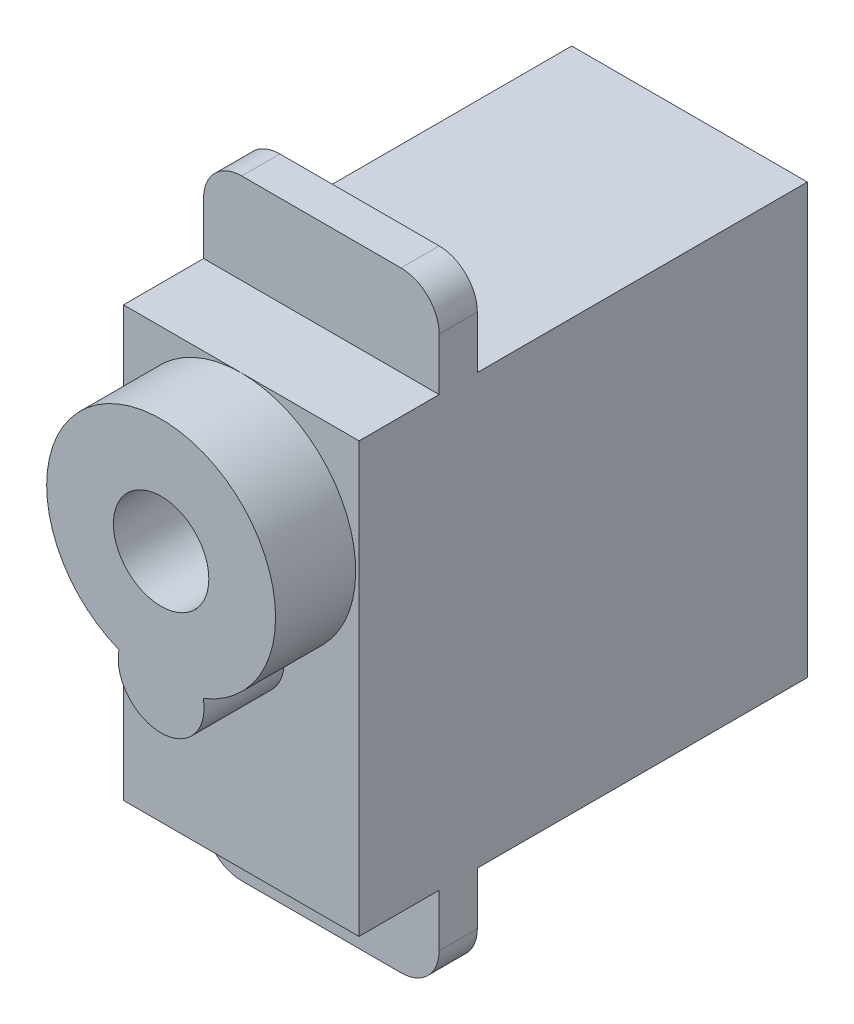
from build123d import *

# Parameters (mm, degrees)
SKETCH3_W           = 22.5
SKETCH3_H           = 23.5
BOSS_EXTRUDE1_DEPTH = 6.175
SKETCH4_W           = 12.35
SKETCH4_H           = 32
BOSS_EXTRUDE2_DEPTH = 2
BOSS_EXTRUDE3_DEPTH = 4.2
SKETCH6_R           = 2.5
CUT_EXTRUDE1_DEPTH  = 4.2
FILLET1_R           = 2


with BuildPart() as part:
    # Sketch3 → Boss-Extrude1 (new body, symmetric)
    with BuildSketch(Plane(origin=(0, -28.275548605, 0), x_dir=(0, 1, 0), z_dir=(1, 0, 0))):
        with Locations((24.609729517, 167.116706922)):
            Rectangle(SKETCH3_W, SKETCH3_H)
    extrude(amount=BOSS_EXTRUDE1_DEPTH, both=True)

    # Sketch4 → Boss-Extrude2 (add)
    with BuildSketch(Plane.XY.offset(174.666706922)):
        with Locations((0, -3.665819089)):
            Rectangle(SKETCH4_W, SKETCH4_H)
    extrude(amount=-BOSS_EXTRUDE2_DEPTH)

    # Sketch5 → Boss-Extrude3 (add)
    with BuildSketch(Plane.XY.offset(178.866706922)):
        with BuildLine():
            ThreePointArc((2.210095356, -3.993944089), (0, 7.584180911), (-2.210095356, -3.993944089))
            ThreePointArc((-2.210095356, -3.993944089), (0, -6.665819089), (2.210095356, -3.993944089))
        make_face()
    extrude(amount=BOSS_EXTRUDE3_DEPTH)

    # Sketch6 → Cut-Extrude1 (cut)
    with BuildSketch(Plane.XY.offset(183.066706922)):
        with Locations((0, 1.584180911)):
            Circle(SKETCH6_R)
    extrude(amount=-CUT_EXTRUDE1_DEPTH, mode=Mode.SUBTRACT)

    # Fillet1
    fillet1_edges = [part.edges().sort_by_distance(p)[0] for p in [
        (-6.175, -19.665819089, 173.666706922),
        (6.175, 12.334180911, 173.666706922),
        (-6.175, 12.334180911, 173.666706922),
        (6.175, -19.665819089, 173.666706922),
    ]]
    fillet(fillet1_edges, radius=FILLET1_R)


solid = part.part
